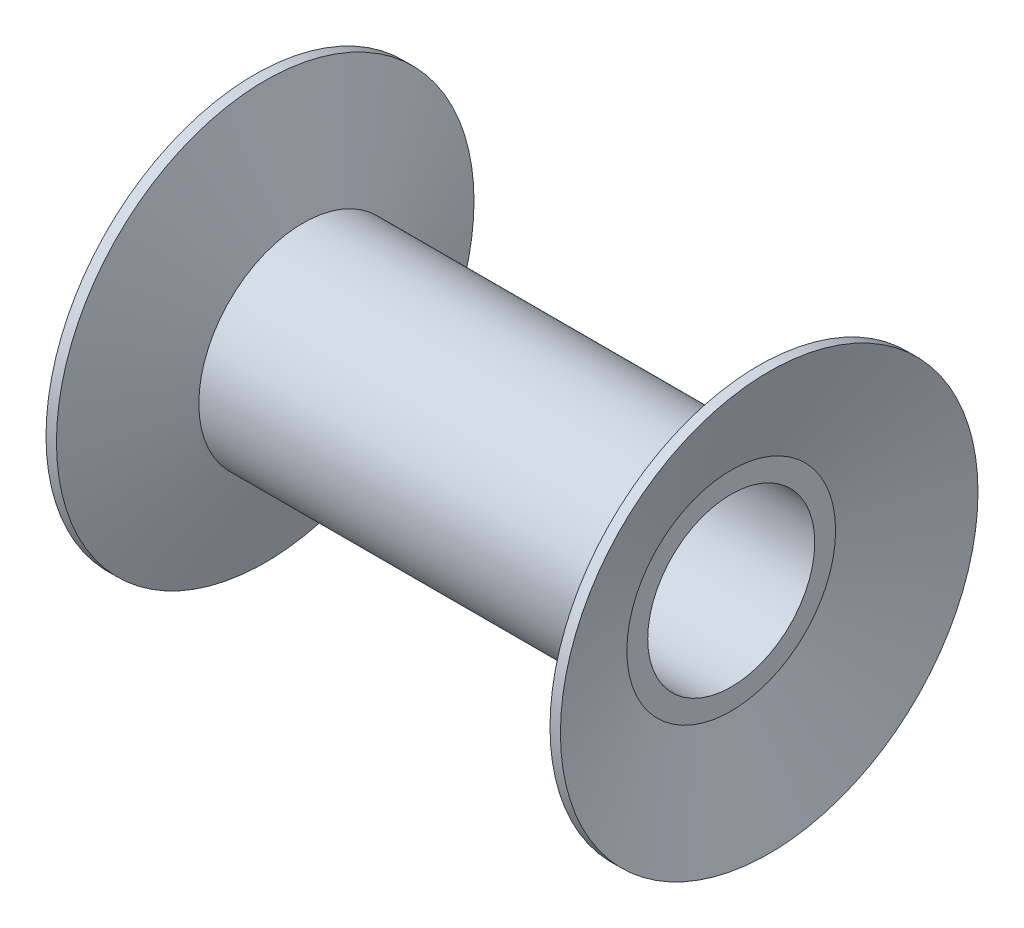
from build123d import *

# Parameters (mm, degrees)
SKETCH4_R               = 40
CUT_EXTRUDE2_DEPTH      = 124.198511713
CUT_EXTRUDE2_DEPTH_BACK = 124.198511713


with BuildPart() as part:
    # Sketch3 → Revolve1 (revolve)
    with BuildSketch(Plane.XY):
        Polygon((100, 50), (-100, 50), (-118.198511713, 100), (-123.198511713, 100), (-105, 50), (-105, 0), (105, 0), (105, 50), (123.198511713, 100), (118.198511713, 100), align=None)
    revolve(axis=Axis((160.387463579, 0, 0), (-1, 0, 0)))

    # Sketch4 → Cut-Extrude2 (cut, two sides)
    with BuildSketch(Plane(origin=(0, 0, 0), x_dir=(0, 0, -1), z_dir=(1, 0, 0))) as cut_extrude2_sk:
        Circle(SKETCH4_R)
    extrude(amount=CUT_EXTRUDE2_DEPTH, mode=Mode.SUBTRACT)
    extrude(cut_extrude2_sk.sketch, amount=-CUT_EXTRUDE2_DEPTH_BACK, mode=Mode.SUBTRACT)


solid = part.part
